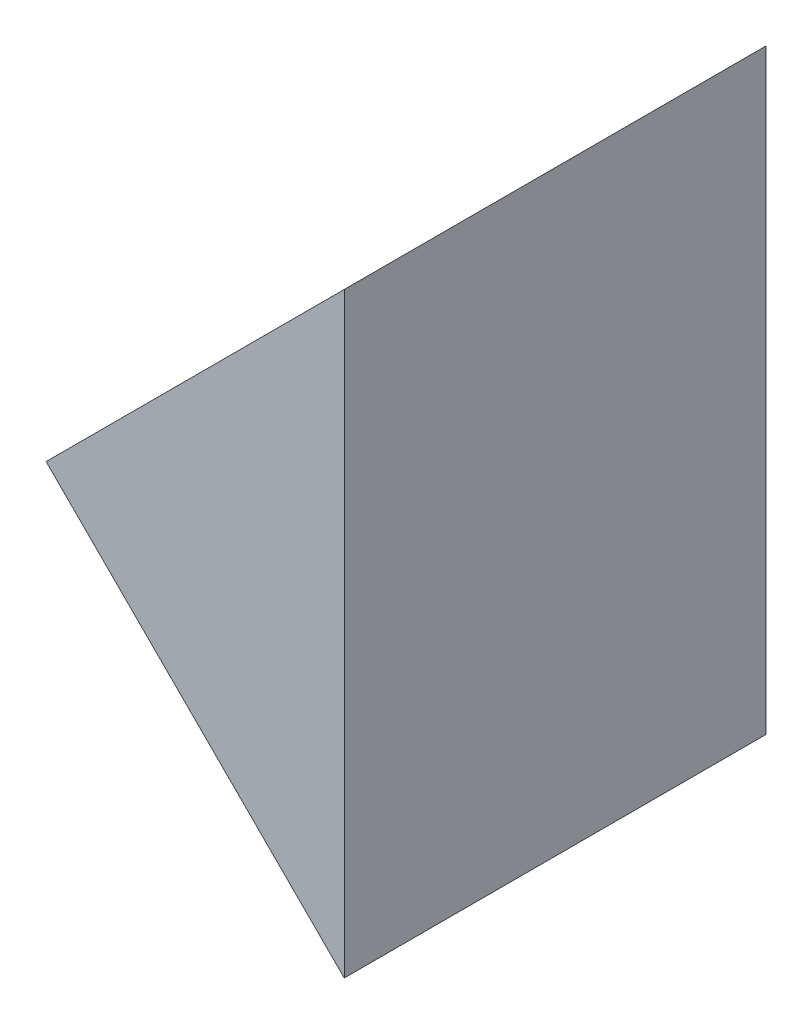
from build123d import *

# Parameters (mm, degrees)
EXTRUDE_1_DEPTH = 40


with BuildPart() as part:
    # 草图1 → 凸台-拉伸1 (new body)
    with BuildSketch(Plane.XY):
        Polygon((563.007194827, 144.27051647), (591.291466075, 172.554787717), (591.291466075, 115.986245222), align=None)
    extrude(amount=EXTRUDE_1_DEPTH)


solid = part.part
